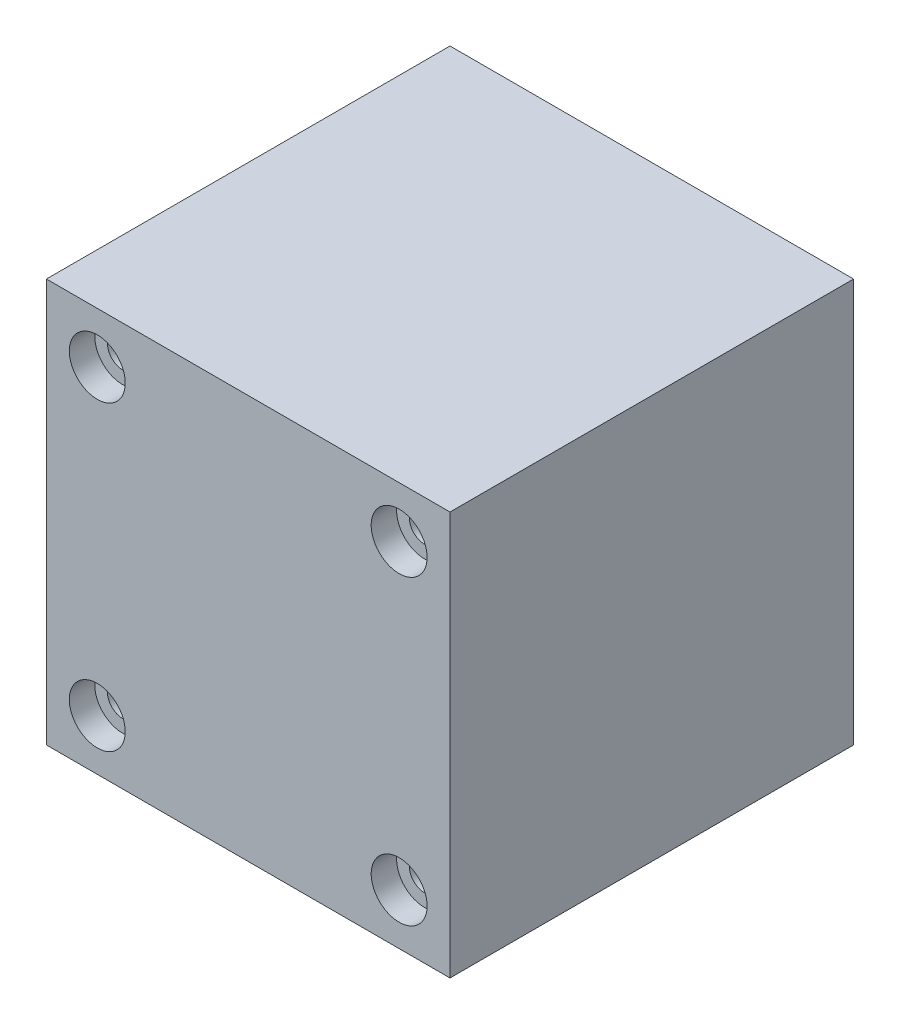
from build123d import *

# Parameters (mm, degrees)
SKETCH1_W                      = 31.75
SKETCH1_H                      = 31.75
BOSS_EXTRUDE1_DEPTH            = 31.75
CBORE_FOR_M2_SHCS1_D           = 2.4
CBORE_FOR_M2_SHCS1_CBORE_D     = 4.4
CBORE_FOR_M2_SHCS1_CBORE_DEPTH = 2


with BuildPart() as part:
    # Sketch1 → Boss-Extrude1 (new body)
    with BuildSketch(Plane.XY):
        Rectangle(SKETCH1_W, SKETCH1_H)
    extrude(amount=BOSS_EXTRUDE1_DEPTH)

    # CBORE for M2 SHCS1 (through all)
    with Locations(Plane.XY.offset(31.75)):
        with Locations((-11.875, 11.875), (11.875, 11.875), (11.875, -11.875), (-11.875, -11.875)):
            CounterBoreHole(CBORE_FOR_M2_SHCS1_D / 2, CBORE_FOR_M2_SHCS1_CBORE_D / 2, CBORE_FOR_M2_SHCS1_CBORE_DEPTH)


solid = part.part
